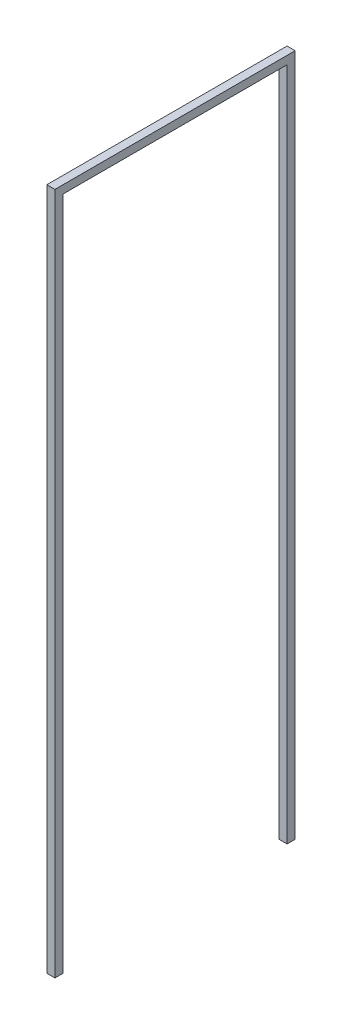
from build123d import *

# Parameters (mm, degrees)
BOSS_EXTRUDE1_DEPTH = 15
SKETCH5_R           = 2.5
BOSS_EXTRUDE3_DEPTH = 2.5


with BuildPart() as part:
    # Sketch2 → Boss-Extrude1 (new body, symmetric)
    with BuildSketch(Plane(origin=(0, 0, 0), x_dir=(0, 0, -1), z_dir=(1, 0, 0))):
        Polygon((0, 0), (0, 2530), (890, 2530), (890, 0), (860, 0), (860, 2500), (30, 2500), (30, 0), align=None)
    extrude(amount=BOSS_EXTRUDE1_DEPTH, both=True)

    # Sketch5 → Boss-Extrude3 (add, symmetric)
    with BuildSketch(Plane.XZ):
        with Locations((0, -15)):
            Circle(SKETCH5_R)
        with Locations((0, -875)):
            Circle(SKETCH5_R)
    extrude(amount=BOSS_EXTRUDE3_DEPTH, both=True)


solid = part.part
